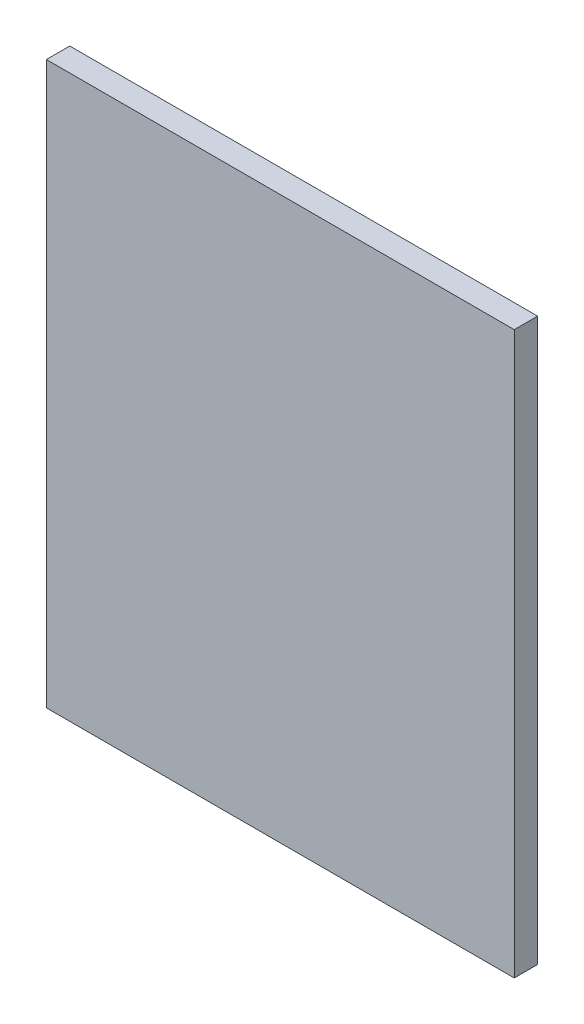
from build123d import *

# Parameters (mm, degrees)
SKETCH2_W           = 63.5
SKETCH2_H           = 76.2
BOSS_EXTRUDE1_DEPTH = 1.5875


with BuildPart() as part:
    # Sketch2 → Boss-Extrude1 (new body, symmetric)
    with BuildSketch(Plane.XY):
        Rectangle(SKETCH2_W, SKETCH2_H)
    extrude(amount=BOSS_EXTRUDE1_DEPTH, both=True)


solid = part.part
